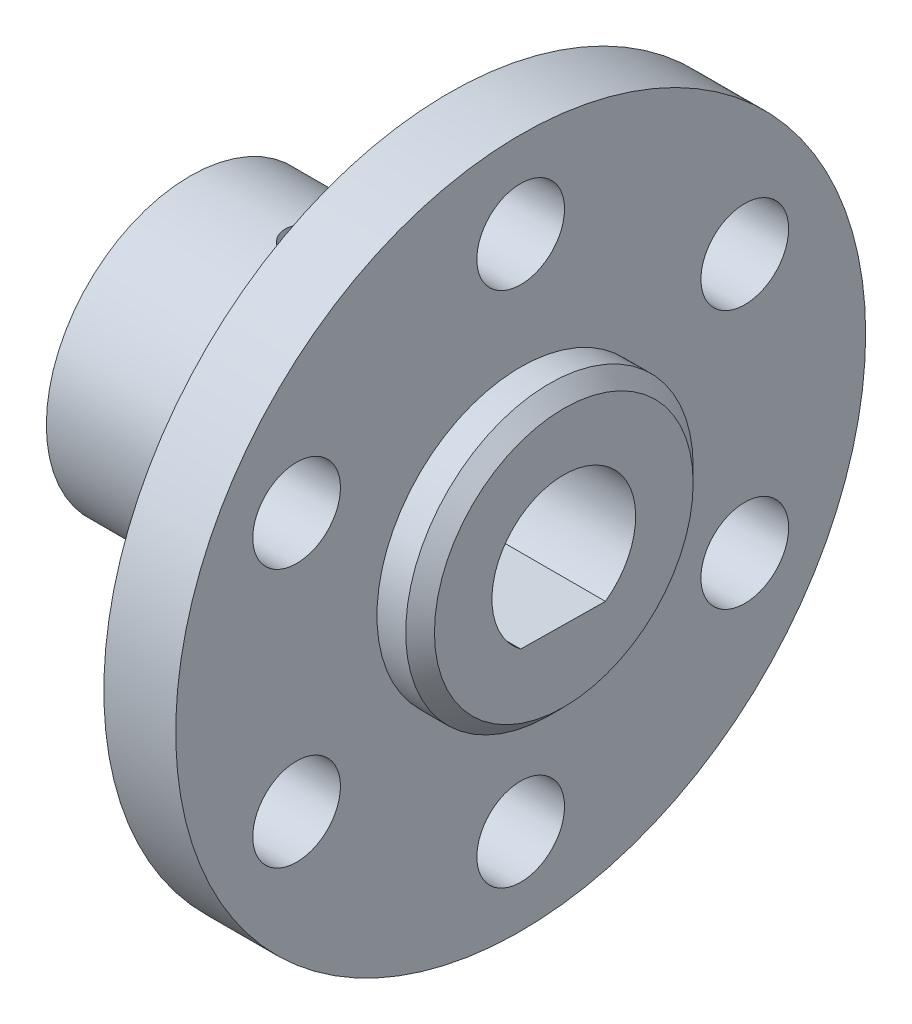
from build123d import *

# Parameters (mm, degrees)
SKETCH_1_R               = 24
SKETCH_1_R_2             = 3.05
EXTRUDE_1_DEPTH          = 5
SKETCH_14_R              = 10
EXTRUDE_2_DEPTH          = 3
SKETCH_15_R              = 10
EXTRUDE_3_DEPTH          = 18
CUT_EXTRUDE_1_DEPTH      = 27
FILLET_5_R               = 3
CHAMFER_1_SIZE           = 1
SKETCH_18_R              = 1.5
CUT_EXTRUDE_4_DEPTH      = 29.344105586
CUT_EXTRUDE_4_DEPTH_BACK = 21.267784004


with BuildPart() as part:
    # Sketch 1 → 凸台-拉伸1 (new body)
    with BuildSketch(Plane(origin=(0, 0, 0), x_dir=(0, 0, -1), z_dir=(1, 0, 0))):
        Circle(SKETCH_1_R)
        with Locations((-15.588457268, 9)):
            Circle(SKETCH_1_R_2, mode=Mode.SUBTRACT)
        with Locations((0, 18)):
            Circle(SKETCH_1_R_2, mode=Mode.SUBTRACT)
        with Locations((15.588457268, 9)):
            Circle(SKETCH_1_R_2, mode=Mode.SUBTRACT)
        with Locations((15.588457268, -9)):
            Circle(SKETCH_1_R_2, mode=Mode.SUBTRACT)
        with Locations((0, -18)):
            Circle(SKETCH_1_R_2, mode=Mode.SUBTRACT)
        with Locations((-15.588457268, -9)):
            Circle(SKETCH_1_R_2, mode=Mode.SUBTRACT)
    extrude(amount=EXTRUDE_1_DEPTH)

    # 草图14 → 凸台-拉伸2 (add)
    with BuildSketch(Plane(origin=(5, 0, 0), x_dir=(0, 0, -1), z_dir=(1, 0, 0))):
        Circle(SKETCH_14_R)
    extrude(amount=EXTRUDE_2_DEPTH)

    # 草图15 → 凸台-拉伸3 (add)
    with BuildSketch(Plane.ZY):
        Circle(SKETCH_15_R)
    extrude(amount=EXTRUDE_3_DEPTH)

    # 草图16 → 切除-拉伸1 (cut, through all)
    with BuildSketch(Plane.ZY.offset(18)):
        with BuildLine():
            ThreePointArc((5, 0), (-2.29326147, 4.443079093), (-2.896380732, -4.075656838))
            Line((-2.896380732, -4.075656838), (3, -4))
            ThreePointArc((3, -4), (4.472135955, -2.236067977), (5, 0))
        make_face()
    extrude(amount=-CUT_EXTRUDE_1_DEPTH, mode=Mode.SUBTRACT)

    # 圆角5
    fillet_5_edges = [part.edges().sort_by_distance(p)[0] for p in [
        (0, 0, -10),
    ]]
    fillet(fillet_5_edges, radius=FILLET_5_R)

    # 倒角1
    chamfer_1_edges = [part.edges().sort_by_distance(p)[0] for p in [
        (8, 0, 10),
    ]]
    chamfer(chamfer_1_edges, length=CHAMFER_1_SIZE)

    # 草图18 → 切除-拉伸4 (cut, two sides)
    with BuildSketch(Plane(origin=(0, -4.037828419, 0.051809634), x_dir=(1, 0, 0), z_dir=(0, 0.999917692, -0.012830008))) as cut_extrude_4_sk:
        with Locations((-10, 0)):
            Circle(SKETCH_18_R)
    extrude(amount=CUT_EXTRUDE_4_DEPTH, mode=Mode.SUBTRACT)
    extrude(cut_extrude_4_sk.sketch, amount=-CUT_EXTRUDE_4_DEPTH_BACK, mode=Mode.SUBTRACT)


solid = part.part
